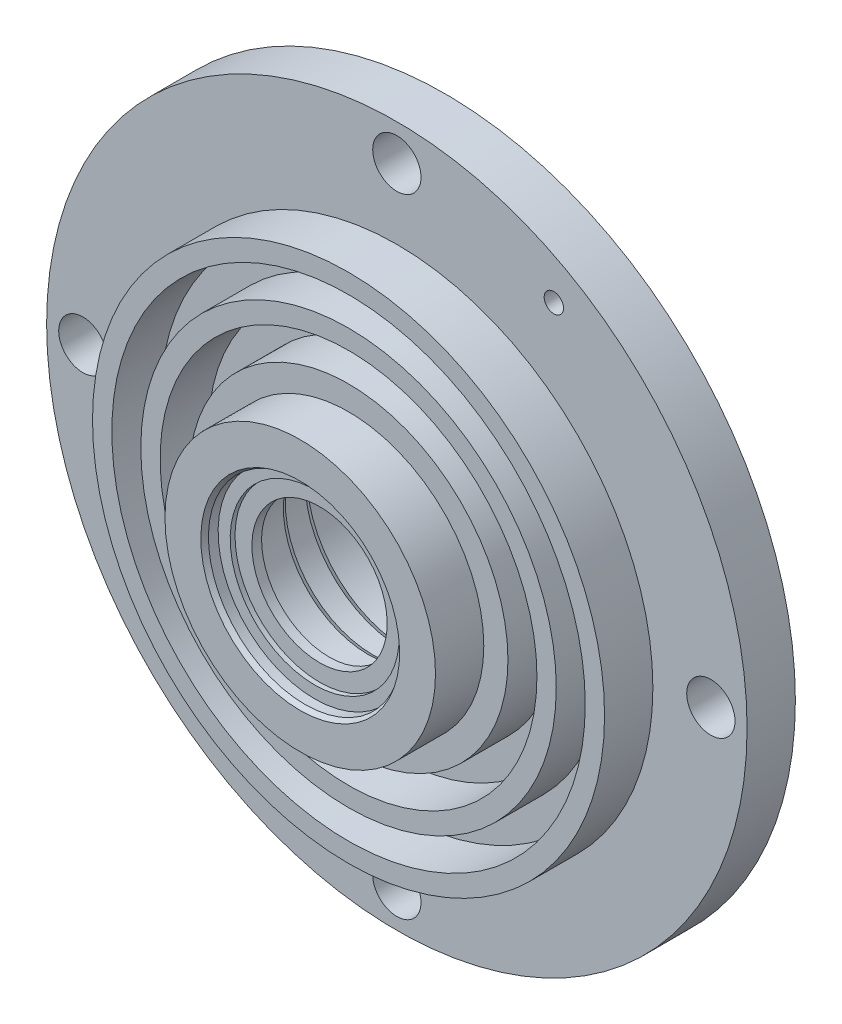
from build123d import *

# Parameters (mm, degrees)
ESQUISSE1_R      = 72.5
ESQUISSE1_R_2    = 5
ESQUISSE1_R_3    = 2
EXTRUSION1_DEPTH = 30


with BuildPart() as part:
    # Esquisse1 → Extrusion1 (new body)
    with BuildSketch(Plane.XY):
        Circle(ESQUISSE1_R)
        with Locations((0, -65)):
            Circle(ESQUISSE1_R_2, mode=Mode.SUBTRACT)
        with Locations((65, 0)):
            Circle(ESQUISSE1_R_2, mode=Mode.SUBTRACT)
        with Locations((0, 65)):
            Circle(ESQUISSE1_R_2, mode=Mode.SUBTRACT)
        with Locations((32.5, 56.291651246)):
            Circle(ESQUISSE1_R_3, mode=Mode.SUBTRACT)
        with Locations((-32.5, -56.291651246)):
            Circle(ESQUISSE1_R_3, mode=Mode.SUBTRACT)
        with Locations((-65, 0)):
            Circle(ESQUISSE1_R_2, mode=Mode.SUBTRACT)
    extrude(amount=-EXTRUSION1_DEPTH)

    # Esquisse2 → Enlèvement de matière-Révolution1 (revolve, cut)
    with BuildSketch(Plane(origin=(0, 0, 0), x_dir=(0, 0, -1), z_dir=(1, 0, 0)), mode=Mode.PRIVATE) as enl_vement_de_mati_re_r_volution1_sk:
        Polygon((14, 15), (15, 15.577350269), (15, 17.5), (21, 17.5), (22, 18.077350269), (22, 18.5), (30, 18.5), (30, -2.5), (0, -2.5), (0, 18.077350269), (1, 17.5), (3, 17.5), (3, 15), (4, 15), (4, 11.5), (6, 11.5), (6, 15), align=None)
    revolve(enl_vement_de_mati_re_r_volution1_sk.sketch.rotate(Axis((0, -2.5, 0), (0, 0, -1)), 180), axis=Axis((0, -2.5, 0), (0, 0, -1)), mode=Mode.SUBTRACT)  # turned: the seam where the file's is

    # Esquisse3 → Enlèvement de matière-Révolution2 (revolve, cut)
    with BuildSketch(Plane(origin=(0, 0, 0), x_dir=(0, 0, -1), z_dir=(1, 0, 0))):
        Polygon((10, -41.5), (10, -45.5), (20, -45.5), (20, -51.5), (10, -51.5), (10, -55.5), (20, -55.5), (20, -82.5), (0, -82.5), (0, -30.5), (10, -30.5), (10, -35.5), (20, -35.5), (20, -41.5), align=None)
    revolve(axis=Axis((0, -2.5, 12.602017423), (0, 0, -1)), mode=Mode.SUBTRACT)


solid = part.part
